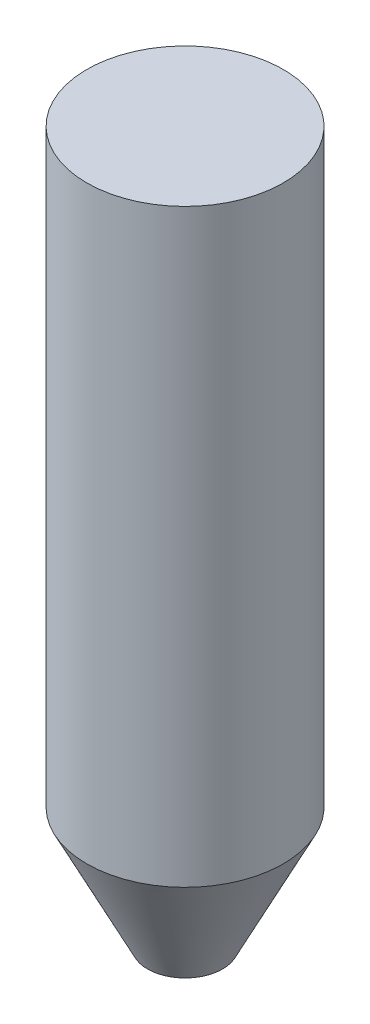
from build123d import *

# Parameters (mm, degrees)
SKETCH2_R               = 19.05
BOSS_EXTRUDE1_DEPTH     = 114.3
CUT_EXTRUDE5_DEPTH      = 143.927827692
CUT_EXTRUDE5_DEPTH_BACK = 143.927827692


with BuildPart() as part:
    # Sketch1 → Revolve1 (revolve)
    with BuildSketch(Plane.XY):
        Polygon((0, 26.065803987), (19.05, 26.065803987), (0, -12.034196013), align=None)
    revolve(axis=Axis((0, 32.664443941, 0), (0, -1, 0)))

    # Sketch2 → Boss-Extrude1 (add)
    with BuildSketch(Plane(origin=(0, 26.065803987, 0), x_dir=(1, 0, 0), z_dir=(0, 1, 0))):
        Circle(SKETCH2_R)
    extrude(amount=BOSS_EXTRUDE1_DEPTH)

    # Sketch4 → Cut-Extrude5 (cut, two sides: drawn at the far end of the back side and taken through both)
    with BuildSketch(Plane.XY.offset(-CUT_EXTRUDE5_DEPTH_BACK)):
        Polygon((-7.278791919, 2.523387825), (7.278791919, 2.523387825), (0, -12.034196013), align=None)
    extrude(amount=CUT_EXTRUDE5_DEPTH + CUT_EXTRUDE5_DEPTH_BACK, mode=Mode.SUBTRACT)


solid = part.part
